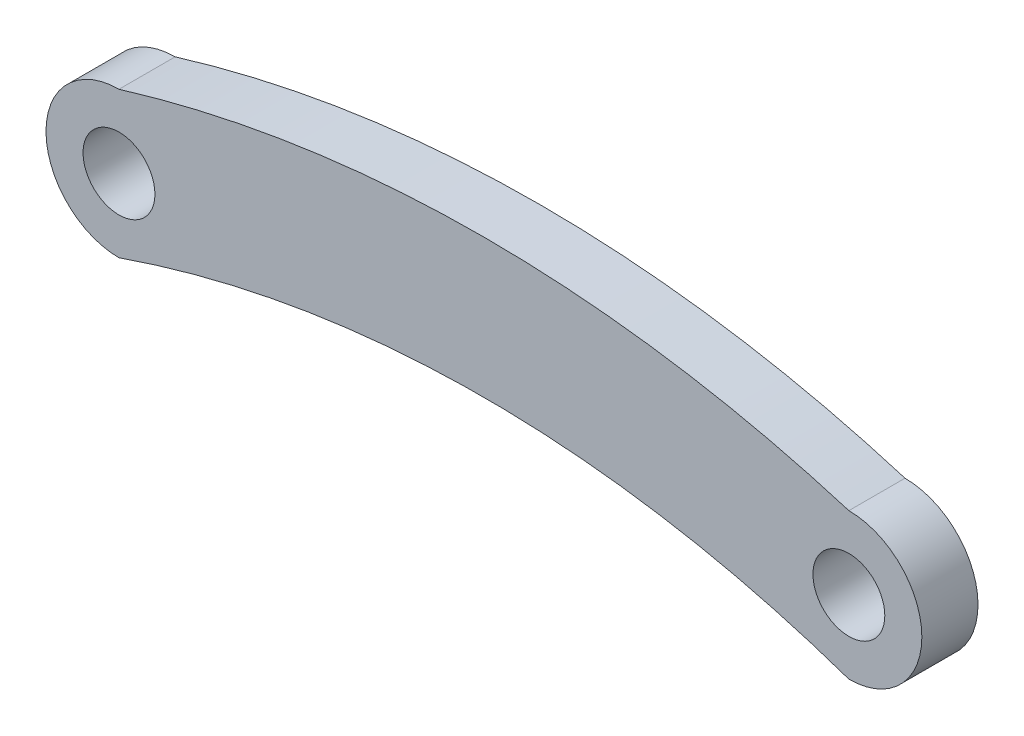
from build123d import *

# Parameters (mm, degrees)
SKETCH1_R           = 1.6
BOSS_EXTRUDE1_DEPTH = 2.5


with BuildPart() as part:
    # Sketch1 → Boss-Extrude1 (new body)
    with BuildSketch(Plane.XY):
        with BuildLine():
            ThreePointArc((-32.5, 3.25), (-35.75, 0), (-32.5, -3.25))
            ThreePointArc((-32.5, -3.25), (-16.25, -0.506313534), (0, -3.25))
            ThreePointArc((0, -3.25), (3.25, 0), (0, 3.25))
            ThreePointArc((0, 3.25), (-16.25, 5.674275927), (-32.5, 3.25))
        make_face()
        with Locations((-32.5, 0)):
            Circle(SKETCH1_R, mode=Mode.SUBTRACT)
        Circle(SKETCH1_R, mode=Mode.SUBTRACT)
    extrude(amount=BOSS_EXTRUDE1_DEPTH)


solid = part.part
